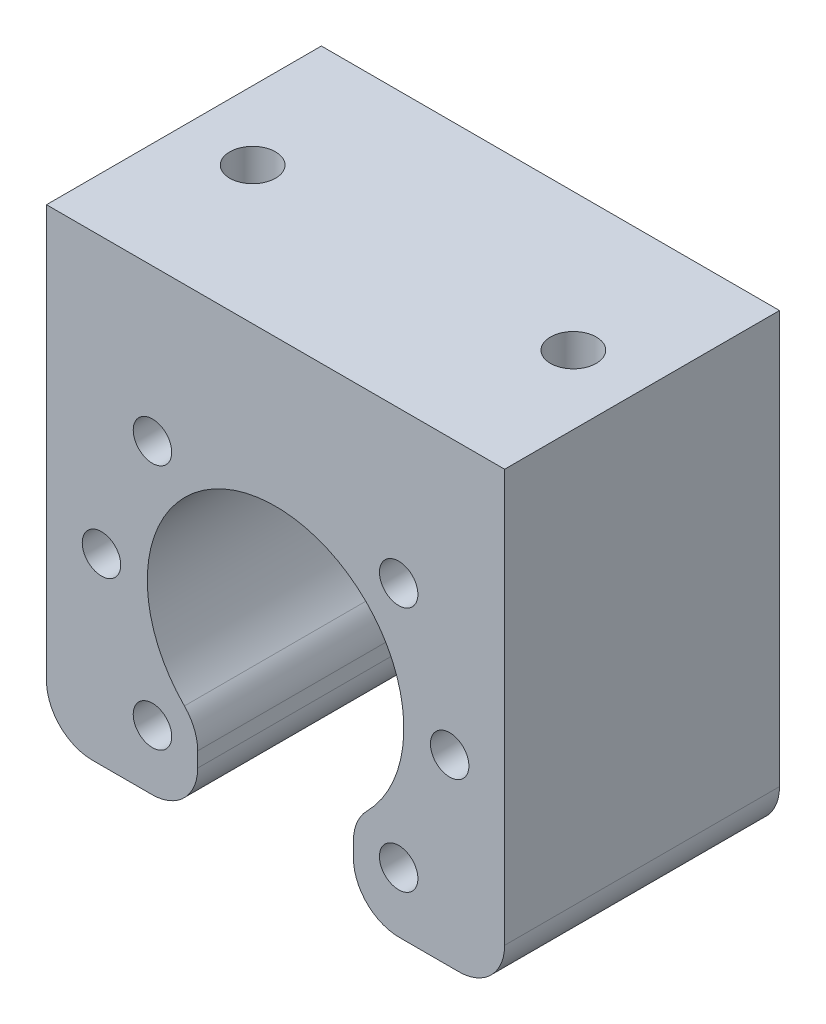
from build123d import *

# Parameters (mm, degrees)
EXTRUDE1_DEPTH        = 30
FILLET1_R             = 5
M5_TAPPED_HOLE1_D     = 4.2
M6_TAPPED_HOLE1_D     = 5
M6_TAPPED_HOLE1_DEPTH = 20
M6_TAPPED_HOLE1_TIP   = 1.502151548


with BuildPart() as part:
    # Sketch1 → Extrude1 (new body)
    with BuildSketch(Plane.XY):
        with BuildLine():
            Line((-25, 30), (25, 30))
            Line((25, 30), (25, -20))
            Line((25, -20), (8.5, -20))
            Line((8.5, -20), (8.5, -11.124297731))
            ThreePointArc((8.5, -11.124297731), (0, 14), (-8.5, -11.124297731))
            Line((-8.5, -11.124297731), (-8.5, -20))
            Line((-8.5, -20), (-25, -20))
            Line((-25, -20), (-25, 30))
        make_face()
    extrude(amount=EXTRUDE1_DEPTH)

    # Fillet1
    fillet1_edges = [part.edges().sort_by_distance(p)[0] for p in [
        (-8.5, -20, 15),
        (-25, -20, 15),
        (25, -20, 15),
        (8.5, -20, 15),
        (8.5, -11.124297731, 15),
        (-8.5, -11.124297731, 15),
    ]]
    fillet(fillet1_edges, radius=FILLET1_R)

    # M5 Tapped Hole1 (through all)
    with Locations(Plane(origin=(0, 0, 0), x_dir=(-1, 0, 0), z_dir=(0, 0, -1))):
        with Locations((-13.435028843, 13.435028843), (13.435028843, 13.435028843), (19, 0), (13.435028843, -13.435028843), (-13.435028843, -13.435028843), (-19, 0)):
            Hole(M5_TAPPED_HOLE1_D / 2)

    # M6 Tapped Hole1
    with Locations(Plane(origin=(0, 30, 0), x_dir=(1, 0, 0), z_dir=(0, 1, 0))):
        with Locations((-17.5, -15), (17.5, -15)):
            Hole(M6_TAPPED_HOLE1_D / 2, depth=M6_TAPPED_HOLE1_DEPTH)
            with Locations((0, 0, -(M6_TAPPED_HOLE1_DEPTH + M6_TAPPED_HOLE1_TIP / 2))):  # 118° drill point
                Cone(0, M6_TAPPED_HOLE1_D / 2, M6_TAPPED_HOLE1_TIP, mode=Mode.SUBTRACT)


solid = part.part
